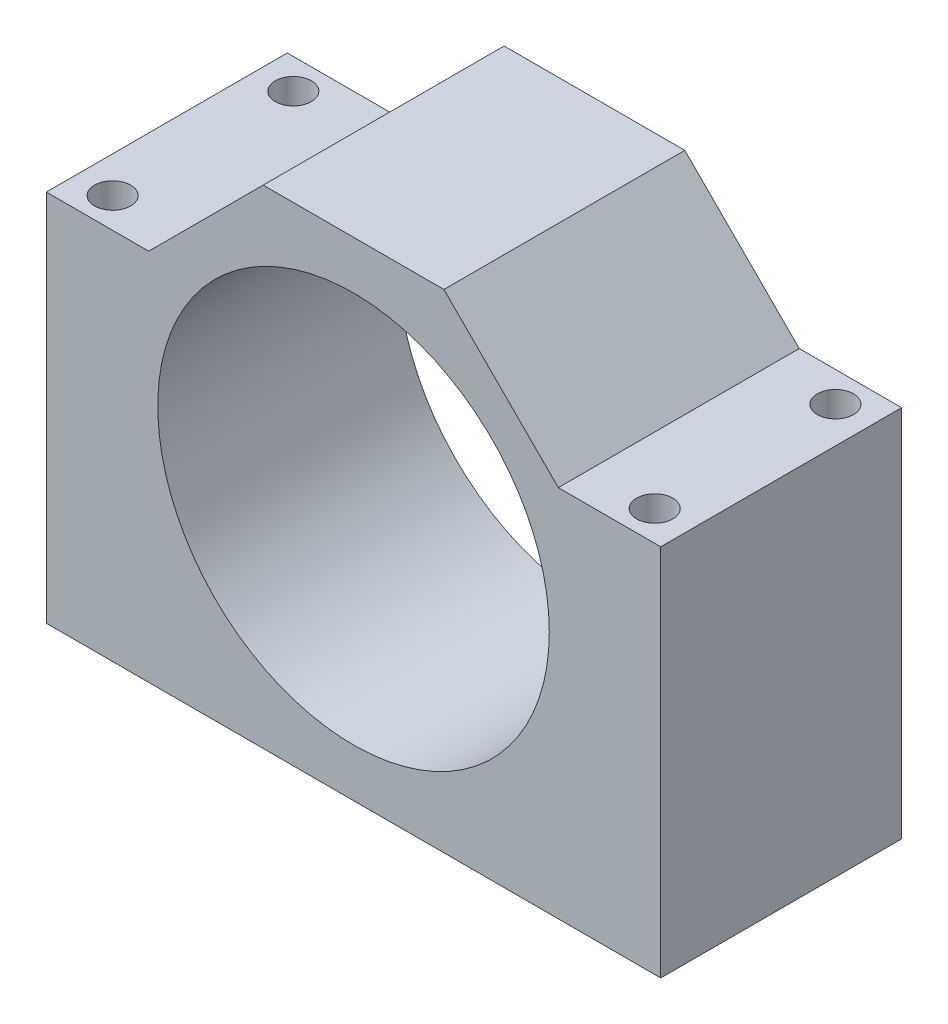
from build123d import *

# Parameters (mm, degrees)
SKETCH1_R           = 32.5
BOSS_EXTRUDE1_DEPTH = 40
SKETCH2_R           = 3
CUT_EXTRUDE1_DEPTH  = 63


with BuildPart() as part:
    # Sketch1 → Boss-Extrude1 (new body)
    with BuildSketch(Plane.XY):
        Polygon((0, 0), (102, 0), (102, 62), (85, 62), (66, 81), (36, 81), (17, 62), (0, 62), align=None)
        with Locations((51, 40.5)):
            Circle(SKETCH1_R, mode=Mode.SUBTRACT)
    extrude(amount=BOSS_EXTRUDE1_DEPTH)

    # Sketch2 → Cut-Extrude1 (cut, through all)
    with BuildSketch(Plane(origin=(0, 62, 0), x_dir=(1, 0, 0), z_dir=(0, 1, 0))):
        with Locations((6, -5)):
            Circle(SKETCH2_R)
        with Locations((6, -35)):
            Circle(SKETCH2_R)
        with Locations((96, -5)):
            Circle(SKETCH2_R)
        with Locations((96, -35)):
            Circle(SKETCH2_R)
    extrude(amount=-CUT_EXTRUDE1_DEPTH, mode=Mode.SUBTRACT)


solid = part.part
